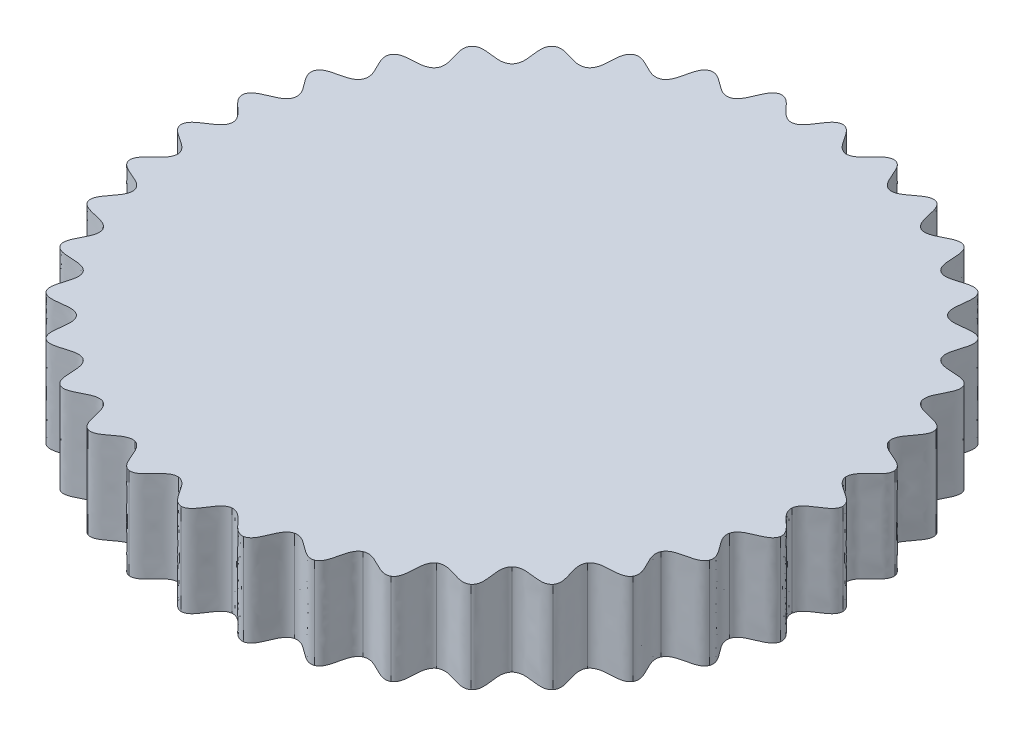
from build123d import *

# Parameters (mm, degrees)
BOSS_EXTRUDE1_DEPTH = 20


with BuildPart() as part:
    # Sketch1 → Boss-Extrude1 (new body)
    with BuildSketch(Plane(origin=(0, 0, 0), x_dir=(1, 0, 0), z_dir=(0, 1, 0))):
        with BuildLine():
            add(Edge.make_bspline(
                [(0, 72.5), (1.314689353, 72.475447897), (2.937173245, 69.807502034), (4.576989429, 67.395832277), (5.883012635, 67.243142121)],
                knots=[0, 0, 0, 0, 0.5, 1, 1, 1, 1], degree=3))
            add(Edge.make_bspline(
                [(12.589492881, 71.398562093), (11.290513185, 71.602676402), (9.229394532, 69.257004003), (7.195708783, 67.166724021), (5.883012635, 67.243142121)],
                knots=[0, 0, 0, 0, 0.5, 1, 1, 1, 1], degree=3))
            add(Edge.make_bspline(
                [(12.589492881, 71.398562093), (13.879945721, 71.146089582), (15.014496499, 68.23693444), (16.210618132, 65.577152274), (17.470285544, 65.199993275)],
                knots=[0, 0, 0, 0, 0.5, 1, 1, 1, 1], degree=3))
            add(Edge.make_bspline(
                [(24.796460391, 68.127715007), (23.552659194, 68.554293818), (21.115531827, 66.602166951), (18.749769024, 64.896788843), (17.470285544, 65.199993275)],
                knots=[0, 0, 0, 0, 0.5, 1, 1, 1, 1], degree=3))
            add(Edge.make_bspline(
                [(24.796460391, 68.127715007), (26.023466961, 67.654993336), (26.635611875, 64.593022123), (27.351695406, 61.765943682), (28.526732667, 61.175775625)],
                knots=[0, 0, 0, 0, 0.5, 1, 1, 1, 1], degree=3))
            add(Edge.make_bspline(
                [(36.25, 62.786841774), (35.099169571, 63.422923706), (32.360084372, 61.923656759), (29.734127021, 60.654997576), (28.526732667, 61.175775625)],
                knots=[0, 0, 0, 0, 0.5, 1, 1, 1, 1], degree=3))
            add(Edge.make_bspline(
                [(36.25, 62.786841774), (37.376278326, 62.108234353), (37.447417662, 58.986483514), (37.661705257, 56.078008147), (38.716409454, 55.29276299)],
                knots=[0, 0, 0, 0, 0.5, 1, 1, 1, 1], degree=3))
            add(Edge.make_bspline(
                [(46.602101702, 55.538222126), (45.579209441, 56.364480151), (42.621392128, 55.36362759), (39.815028614, 54.5702349), (38.716409454, 55.29276299)],
                knots=[0, 0, 0, 0, 0.5, 1, 1, 1, 1], degree=3))
            add(Edge.make_bspline(
                [(46.602101702, 55.538222126), (47.593430388, 54.674348097), (47.121402613, 51.587670452), (46.82738325, 48.686170711), (47.72970773, 47.72970773)],
                knots=[0, 0, 0, 0, 0.5, 1, 1, 1, 1], degree=3))
            add(Edge.make_bspline(
                [(55.538222126, 46.602101702), (54.674348097, 47.593430388), (51.587670452, 47.121402613), (48.686170711, 46.82738325), (47.72970773, 47.72970773)],
                knots=[0, 0, 0, 0, 0.5, 1, 1, 1, 1], degree=3))
            add(Edge.make_bspline(
                [(55.538222126, 46.602101702), (56.364480151, 45.579209441), (55.36362759, 42.621392128), (54.5702349, 39.815028614), (55.29276299, 38.716409454)],
                knots=[0, 0, 0, 0, 0.5, 1, 1, 1, 1], degree=3))
            add(Edge.make_bspline(
                [(62.786841774, 36.25), (62.108234353, 37.376278326), (58.986483514, 37.447417662), (56.078008147, 37.661705257), (55.29276299, 38.716409454)],
                knots=[0, 0, 0, 0, 0.5, 1, 1, 1, 1], degree=3))
            add(Edge.make_bspline(
                [(62.786841774, 36.25), (63.422923706, 35.099169571), (61.923656759, 32.360084372), (60.654997576, 29.734127021), (61.175775625, 28.526732667)],
                knots=[0, 0, 0, 0, 0.5, 1, 1, 1, 1], degree=3))
            add(Edge.make_bspline(
                [(68.127715007, 24.796460391), (67.654993336, 26.023466961), (64.593022123, 26.635611875), (61.765943682, 27.351695406), (61.175775625, 28.526732667)],
                knots=[0, 0, 0, 0, 0.5, 1, 1, 1, 1], degree=3))
            add(Edge.make_bspline(
                [(68.127715007, 24.796460391), (68.554293818, 23.552659194), (66.602166951, 21.115531827), (64.896788843, 18.749769024), (65.199993275, 17.470285544)],
                knots=[0, 0, 0, 0, 0.5, 1, 1, 1, 1], degree=3))
            add(Edge.make_bspline(
                [(71.398562093, 12.589492881), (71.146089582, 13.879945721), (68.23693444, 15.014496499), (65.577152274, 16.210618132), (65.199993275, 17.470285544)],
                knots=[0, 0, 0, 0, 0.5, 1, 1, 1, 1], degree=3))
            add(Edge.make_bspline(
                [(71.398562093, 12.589492881), (71.602676402, 11.290513185), (69.257004003, 9.229394532), (67.166724021, 7.195708783), (67.243142121, 5.883012635)],
                knots=[0, 0, 0, 0, 0.5, 1, 1, 1, 1], degree=3))
            add(Edge.make_bspline(
                [(72.5, 0), (72.475447897, 1.314689353), (69.807502034, 2.937173245), (67.395832277, 4.576989429), (67.243142121, 5.883012635)],
                knots=[0, 0, 0, 0, 0.5, 1, 1, 1, 1], degree=3))
            add(Edge.make_bspline(
                [(72.5, 0), (72.475447897, -1.314689353), (69.807502034, -2.937173245), (67.395832277, -4.576989429), (67.243142121, -5.883012635)],
                knots=[0, 0, 0, 0, 0.5, 1, 1, 1, 1], degree=3))
            add(Edge.make_bspline(
                [(71.398562093, -12.589492881), (71.602676402, -11.290513185), (69.257004003, -9.229394532), (67.166724021, -7.195708783), (67.243142121, -5.883012635)],
                knots=[0, 0, 0, 0, 0.5, 1, 1, 1, 1], degree=3))
            add(Edge.make_bspline(
                [(71.398562093, -12.589492881), (71.146089582, -13.879945721), (68.23693444, -15.014496499), (65.577152274, -16.210618132), (65.199993275, -17.470285544)],
                knots=[0, 0, 0, 0, 0.5, 1, 1, 1, 1], degree=3))
            add(Edge.make_bspline(
                [(68.127715007, -24.796460391), (68.554293818, -23.552659194), (66.602166951, -21.115531827), (64.896788843, -18.749769024), (65.199993275, -17.470285544)],
                knots=[0, 0, 0, 0, 0.5, 1, 1, 1, 1], degree=3))
            add(Edge.make_bspline(
                [(68.127715007, -24.796460391), (67.654993336, -26.023466961), (64.593022123, -26.635611875), (61.765943682, -27.351695406), (61.175775625, -28.526732667)],
                knots=[0, 0, 0, 0, 0.5, 1, 1, 1, 1], degree=3))
            add(Edge.make_bspline(
                [(62.786841774, -36.25), (63.422923706, -35.099169571), (61.923656759, -32.360084372), (60.654997576, -29.734127021), (61.175775625, -28.526732667)],
                knots=[0, 0, 0, 0, 0.5, 1, 1, 1, 1], degree=3))
            add(Edge.make_bspline(
                [(62.786841774, -36.25), (62.108234353, -37.376278326), (58.986483514, -37.447417662), (56.078008147, -37.661705257), (55.29276299, -38.716409454)],
                knots=[0, 0, 0, 0, 0.5, 1, 1, 1, 1], degree=3))
            add(Edge.make_bspline(
                [(55.538222126, -46.602101702), (56.364480151, -45.579209441), (55.36362759, -42.621392128), (54.5702349, -39.815028614), (55.29276299, -38.716409454)],
                knots=[0, 0, 0, 0, 0.5, 1, 1, 1, 1], degree=3))
            add(Edge.make_bspline(
                [(55.538222126, -46.602101702), (54.674348097, -47.593430388), (51.587670452, -47.121402613), (48.686170711, -46.82738325), (47.72970773, -47.72970773)],
                knots=[0, 0, 0, 0, 0.5, 1, 1, 1, 1], degree=3))
            add(Edge.make_bspline(
                [(46.602101702, -55.538222126), (47.593430388, -54.674348097), (47.121402613, -51.587670452), (46.82738325, -48.686170711), (47.72970773, -47.72970773)],
                knots=[0, 0, 0, 0, 0.5, 1, 1, 1, 1], degree=3))
            add(Edge.make_bspline(
                [(46.602101702, -55.538222126), (45.579209441, -56.364480151), (42.621392128, -55.36362759), (39.815028614, -54.5702349), (38.716409454, -55.29276299)],
                knots=[0, 0, 0, 0, 0.5, 1, 1, 1, 1], degree=3))
            add(Edge.make_bspline(
                [(36.25, -62.786841774), (37.376278326, -62.108234353), (37.447417662, -58.986483514), (37.661705257, -56.078008147), (38.716409454, -55.29276299)],
                knots=[0, 0, 0, 0, 0.5, 1, 1, 1, 1], degree=3))
            add(Edge.make_bspline(
                [(36.25, -62.786841774), (35.099169571, -63.422923706), (32.360084372, -61.923656759), (29.734127021, -60.654997576), (28.526732667, -61.175775625)],
                knots=[0, 0, 0, 0, 0.5, 1, 1, 1, 1], degree=3))
            add(Edge.make_bspline(
                [(24.796460391, -68.127715007), (26.023466961, -67.654993336), (26.635611875, -64.593022123), (27.351695406, -61.765943682), (28.526732667, -61.175775625)],
                knots=[0, 0, 0, 0, 0.5, 1, 1, 1, 1], degree=3))
            add(Edge.make_bspline(
                [(24.796460391, -68.127715007), (23.552659194, -68.554293818), (21.115531827, -66.602166951), (18.749769024, -64.896788843), (17.470285544, -65.199993275)],
                knots=[0, 0, 0, 0, 0.5, 1, 1, 1, 1], degree=3))
            add(Edge.make_bspline(
                [(12.589492881, -71.398562093), (13.879945721, -71.146089582), (15.014496499, -68.23693444), (16.210618132, -65.577152274), (17.470285544, -65.199993275)],
                knots=[0, 0, 0, 0, 0.5, 1, 1, 1, 1], degree=3))
            add(Edge.make_bspline(
                [(12.589492881, -71.398562093), (11.290513185, -71.602676402), (9.229394532, -69.257004003), (7.195708783, -67.166724021), (5.883012635, -67.243142121)],
                knots=[0, 0, 0, 0, 0.5, 1, 1, 1, 1], degree=3))
            add(Edge.make_bspline(
                [(0, -72.5), (1.314689353, -72.475447897), (2.937173245, -69.807502034), (4.576989429, -67.395832277), (5.883012635, -67.243142121)],
                knots=[0, 0, 0, 0, 0.5, 1, 1, 1, 1], degree=3))
            add(Edge.make_bspline(
                [(0, -72.5), (-1.314689353, -72.475447897), (-2.937173245, -69.807502034), (-4.576989429, -67.395832277), (-5.883012635, -67.243142121)],
                knots=[0, 0, 0, 0, 0.5, 1, 1, 1, 1], degree=3))
            add(Edge.make_bspline(
                [(-12.589492881, -71.398562093), (-11.290513185, -71.602676402), (-9.229394532, -69.257004003), (-7.195708783, -67.166724021), (-5.883012635, -67.243142121)],
                knots=[0, 0, 0, 0, 0.5, 1, 1, 1, 1], degree=3))
            add(Edge.make_bspline(
                [(-12.589492881, -71.398562093), (-13.879945721, -71.146089582), (-15.014496499, -68.23693444), (-16.210618132, -65.577152274), (-17.470285544, -65.199993275)],
                knots=[0, 0, 0, 0, 0.5, 1, 1, 1, 1], degree=3))
            add(Edge.make_bspline(
                [(-24.796460391, -68.127715007), (-23.552659194, -68.554293818), (-21.115531827, -66.602166951), (-18.749769024, -64.896788843), (-17.470285544, -65.199993275)],
                knots=[0, 0, 0, 0, 0.5, 1, 1, 1, 1], degree=3))
            add(Edge.make_bspline(
                [(-24.796460391, -68.127715007), (-26.023466961, -67.654993336), (-26.635611875, -64.593022123), (-27.351695406, -61.765943682), (-28.526732667, -61.175775625)],
                knots=[0, 0, 0, 0, 0.5, 1, 1, 1, 1], degree=3))
            add(Edge.make_bspline(
                [(-36.25, -62.786841774), (-35.099169571, -63.422923706), (-32.360084372, -61.923656759), (-29.734127021, -60.654997576), (-28.526732667, -61.175775625)],
                knots=[0, 0, 0, 0, 0.5, 1, 1, 1, 1], degree=3))
            add(Edge.make_bspline(
                [(-36.25, -62.786841774), (-37.376278326, -62.108234353), (-37.447417662, -58.986483514), (-37.661705257, -56.078008147), (-38.716409454, -55.29276299)],
                knots=[0, 0, 0, 0, 0.5, 1, 1, 1, 1], degree=3))
            add(Edge.make_bspline(
                [(-46.602101702, -55.538222126), (-45.579209441, -56.364480151), (-42.621392128, -55.36362759), (-39.815028614, -54.5702349), (-38.716409454, -55.29276299)],
                knots=[0, 0, 0, 0, 0.5, 1, 1, 1, 1], degree=3))
            add(Edge.make_bspline(
                [(-46.602101702, -55.538222126), (-47.593430388, -54.674348097), (-47.121402613, -51.587670452), (-46.82738325, -48.686170711), (-47.72970773, -47.72970773)],
                knots=[0, 0, 0, 0, 0.5, 1, 1, 1, 1], degree=3))
            add(Edge.make_bspline(
                [(-55.538222126, -46.602101702), (-54.674348097, -47.593430388), (-51.587670452, -47.121402613), (-48.686170711, -46.82738325), (-47.72970773, -47.72970773)],
                knots=[0, 0, 0, 0, 0.5, 1, 1, 1, 1], degree=3))
            add(Edge.make_bspline(
                [(-55.538222126, -46.602101702), (-56.364480151, -45.579209441), (-55.36362759, -42.621392128), (-54.5702349, -39.815028614), (-55.29276299, -38.716409454)],
                knots=[0, 0, 0, 0, 0.5, 1, 1, 1, 1], degree=3))
            add(Edge.make_bspline(
                [(-62.786841774, -36.25), (-62.108234353, -37.376278326), (-58.986483514, -37.447417662), (-56.078008147, -37.661705257), (-55.29276299, -38.716409454)],
                knots=[0, 0, 0, 0, 0.5, 1, 1, 1, 1], degree=3))
            add(Edge.make_bspline(
                [(-62.786841774, -36.25), (-63.422923706, -35.099169571), (-61.923656759, -32.360084372), (-60.654997576, -29.734127021), (-61.175775625, -28.526732667)],
                knots=[0, 0, 0, 0, 0.5, 1, 1, 1, 1], degree=3))
            add(Edge.make_bspline(
                [(-68.127715007, -24.796460391), (-67.654993336, -26.023466961), (-64.593022123, -26.635611875), (-61.765943682, -27.351695406), (-61.175775625, -28.526732667)],
                knots=[0, 0, 0, 0, 0.5, 1, 1, 1, 1], degree=3))
            add(Edge.make_bspline(
                [(-68.127715007, -24.796460391), (-68.554293818, -23.552659194), (-66.602166951, -21.115531827), (-64.896788843, -18.749769024), (-65.199993275, -17.470285544)],
                knots=[0, 0, 0, 0, 0.5, 1, 1, 1, 1], degree=3))
            add(Edge.make_bspline(
                [(-71.398562093, -12.589492881), (-71.146089582, -13.879945721), (-68.23693444, -15.014496499), (-65.577152274, -16.210618132), (-65.199993275, -17.470285544)],
                knots=[0, 0, 0, 0, 0.5, 1, 1, 1, 1], degree=3))
            add(Edge.make_bspline(
                [(-71.398562093, -12.589492881), (-71.602676402, -11.290513185), (-69.257004003, -9.229394532), (-67.166724021, -7.195708783), (-67.243142121, -5.883012635)],
                knots=[0, 0, 0, 0, 0.5, 1, 1, 1, 1], degree=3))
            add(Edge.make_bspline(
                [(-72.5, 0), (-72.475447897, -1.314689353), (-69.807502034, -2.937173245), (-67.395832277, -4.576989429), (-67.243142121, -5.883012635)],
                knots=[0, 0, 0, 0, 0.5, 1, 1, 1, 1], degree=3))
            add(Edge.make_bspline(
                [(-72.5, 0), (-72.475447897, 1.314689353), (-69.807502034, 2.937173245), (-67.395832277, 4.576989429), (-67.243142121, 5.883012635)],
                knots=[0, 0, 0, 0, 0.5, 1, 1, 1, 1], degree=3))
            add(Edge.make_bspline(
                [(-71.398562093, 12.589492881), (-71.602676402, 11.290513185), (-69.257004003, 9.229394532), (-67.166724021, 7.195708783), (-67.243142121, 5.883012635)],
                knots=[0, 0, 0, 0, 0.5, 1, 1, 1, 1], degree=3))
            add(Edge.make_bspline(
                [(-71.398562093, 12.589492881), (-71.146089582, 13.879945721), (-68.23693444, 15.014496499), (-65.577152274, 16.210618132), (-65.199993275, 17.470285544)],
                knots=[0, 0, 0, 0, 0.5, 1, 1, 1, 1], degree=3))
            add(Edge.make_bspline(
                [(-68.127715007, 24.796460391), (-68.554293818, 23.552659194), (-66.602166951, 21.115531827), (-64.896788843, 18.749769024), (-65.199993275, 17.470285544)],
                knots=[0, 0, 0, 0, 0.5, 1, 1, 1, 1], degree=3))
            add(Edge.make_bspline(
                [(-68.127715007, 24.796460391), (-67.654993336, 26.023466961), (-64.593022123, 26.635611875), (-61.765943682, 27.351695406), (-61.175775625, 28.526732667)],
                knots=[0, 0, 0, 0, 0.5, 1, 1, 1, 1], degree=3))
            add(Edge.make_bspline(
                [(-62.786841774, 36.25), (-63.422923706, 35.099169571), (-61.923656759, 32.360084372), (-60.654997576, 29.734127021), (-61.175775625, 28.526732667)],
                knots=[0, 0, 0, 0, 0.5, 1, 1, 1, 1], degree=3))
            add(Edge.make_bspline(
                [(-62.786841774, 36.25), (-62.108234353, 37.376278326), (-58.986483514, 37.447417662), (-56.078008147, 37.661705257), (-55.29276299, 38.716409454)],
                knots=[0, 0, 0, 0, 0.5, 1, 1, 1, 1], degree=3))
            add(Edge.make_bspline(
                [(-55.538222126, 46.602101702), (-56.364480151, 45.579209441), (-55.36362759, 42.621392128), (-54.5702349, 39.815028614), (-55.29276299, 38.716409454)],
                knots=[0, 0, 0, 0, 0.5, 1, 1, 1, 1], degree=3))
            add(Edge.make_bspline(
                [(-55.538222126, 46.602101702), (-54.674348097, 47.593430388), (-51.587670452, 47.121402613), (-48.686170711, 46.82738325), (-47.72970773, 47.72970773)],
                knots=[0, 0, 0, 0, 0.5, 1, 1, 1, 1], degree=3))
            add(Edge.make_bspline(
                [(-46.602101702, 55.538222126), (-47.593430388, 54.674348097), (-47.121402613, 51.587670452), (-46.82738325, 48.686170711), (-47.72970773, 47.72970773)],
                knots=[0, 0, 0, 0, 0.5, 1, 1, 1, 1], degree=3))
            add(Edge.make_bspline(
                [(-46.602101702, 55.538222126), (-45.579209441, 56.364480151), (-42.621392128, 55.36362759), (-39.815028614, 54.5702349), (-38.716409454, 55.29276299)],
                knots=[0, 0, 0, 0, 0.5, 1, 1, 1, 1], degree=3))
            add(Edge.make_bspline(
                [(-36.25, 62.786841774), (-37.376278326, 62.108234353), (-37.447417662, 58.986483514), (-37.661705257, 56.078008147), (-38.716409454, 55.29276299)],
                knots=[0, 0, 0, 0, 0.5, 1, 1, 1, 1], degree=3))
            add(Edge.make_bspline(
                [(-36.25, 62.786841774), (-35.099169571, 63.422923706), (-32.360084372, 61.923656759), (-29.734127021, 60.654997576), (-28.526732667, 61.175775625)],
                knots=[0, 0, 0, 0, 0.5, 1, 1, 1, 1], degree=3))
            add(Edge.make_bspline(
                [(-24.796460391, 68.127715007), (-26.023466961, 67.654993336), (-26.635611875, 64.593022123), (-27.351695406, 61.765943682), (-28.526732667, 61.175775625)],
                knots=[0, 0, 0, 0, 0.5, 1, 1, 1, 1], degree=3))
            add(Edge.make_bspline(
                [(-24.796460391, 68.127715007), (-23.552659194, 68.554293818), (-21.115531827, 66.602166951), (-18.749769024, 64.896788843), (-17.470285544, 65.199993275)],
                knots=[0, 0, 0, 0, 0.5, 1, 1, 1, 1], degree=3))
            add(Edge.make_bspline(
                [(-12.589492881, 71.398562093), (-13.879945721, 71.146089582), (-15.014496499, 68.23693444), (-16.210618132, 65.577152274), (-17.470285544, 65.199993275)],
                knots=[0, 0, 0, 0, 0.5, 1, 1, 1, 1], degree=3))
            add(Edge.make_bspline(
                [(-12.589492881, 71.398562093), (-11.290513185, 71.602676402), (-9.229394532, 69.257004003), (-7.195708783, 67.166724021), (-5.883012635, 67.243142121)],
                knots=[0, 0, 0, 0, 0.5, 1, 1, 1, 1], degree=3))
            add(Edge.make_bspline(
                [(0, 72.5), (-1.314689353, 72.475447897), (-2.937173245, 69.807502034), (-4.576989429, 67.395832277), (-5.883012635, 67.243142121)],
                knots=[0, 0, 0, 0, 0.5, 1, 1, 1, 1], degree=3))
        make_face()
    extrude(amount=BOSS_EXTRUDE1_DEPTH)


solid = part.part
